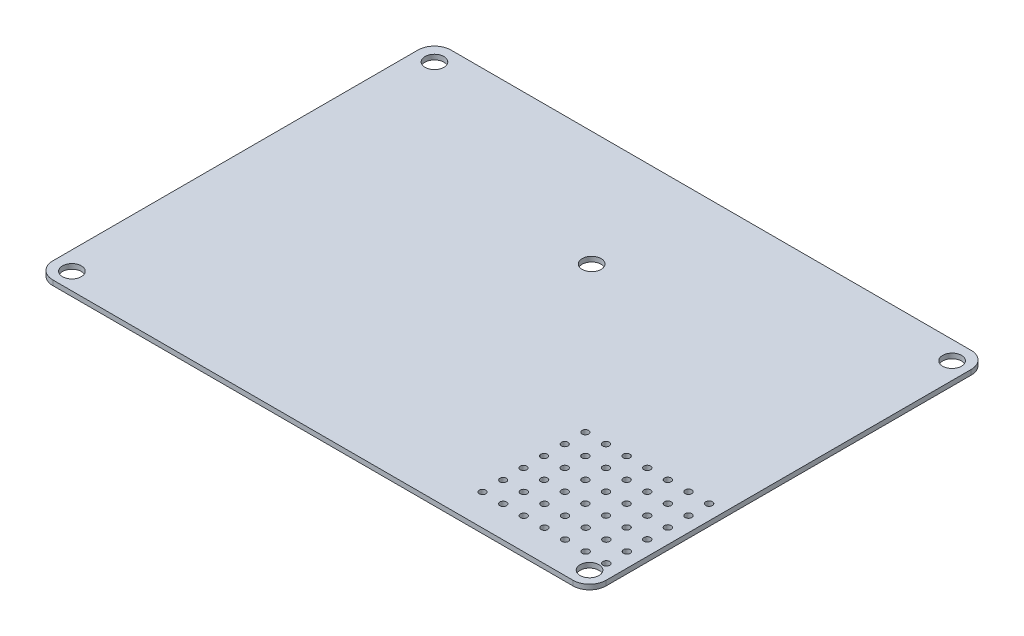
from build123d import *

# Parameters (mm, degrees)
EXTRUSION1_DEPTH        = 1.2
ENL_V_MAT_EXTRU_2_REACH = 3.2
TROUS_FIXATION_R        = 2.286
ESQUISSE4_R             = 0.786015169
ESQUISSE4_R_2           = 0.803384231
ESQUISSE4_R_3           = 0.807067653
ESQUISSE4_R_4           = 0.813396678
ENL_V_MAT_EXTRU_3_DEPTH = 1.2


with BuildPart() as part:
    # Carte → Extrusion1 (new body)
    with BuildSketch(Plane(origin=(0, 0, 0), x_dir=(1, 0, 0), z_dir=(0, 1, 0))):
        with BuildLine():
            Line((4, 0), (130.112, 0))
            ThreePointArc((130.112, 0), (132.940427125, -1.171572875), (134.112, -4))
            Line((134.112, -4), (134.112, -92.52))
            ThreePointArc((134.112, -92.52), (132.940427125, -95.348427125), (130.112, -96.52))
            Line((130.112, -96.52), (4, -96.52))
            ThreePointArc((4, -96.52), (1.171572875, -95.348427125), (0, -92.52))
            Line((0, -92.52), (0, -4))
            ThreePointArc((0, -4), (1.171572875, -1.171572875), (4, 0))
        make_face()
    extrude(amount=EXTRUSION1_DEPTH)

    # Trous fixation → Enlèv. mat.-Extru.2 (cut, up to next)
    with BuildSketch(Plane(origin=(0, 1.2, 0), x_dir=(1, 0, 0), z_dir=(0, 1, 0)), mode=Mode.PRIVATE) as enl_v_mat_extru_2_sk1:
        with Locations((4.5, -4.5)):
            Circle(TROUS_FIXATION_R)
    enl_v_mat_extru_2_tool1 = extrude(enl_v_mat_extru_2_sk1.sketch, amount=-ENL_V_MAT_EXTRU_2_REACH, mode=Mode.PRIVATE) & part.part
    add(enl_v_mat_extru_2_tool1.solids().sort_by_distance((4.5, 1.2, 4.5))[0], mode=Mode.SUBTRACT)
    # Trous fixation → Enlèv. mat.-Extru.2 (cut, up to next)
    with BuildSketch(Plane(origin=(0, 1.2, 0), x_dir=(1, 0, 0), z_dir=(0, 1, 0)), mode=Mode.PRIVATE) as enl_v_mat_extru_2_sk2:
        with Locations((129.976, -4.5)):
            Circle(TROUS_FIXATION_R)
    enl_v_mat_extru_2_tool2 = extrude(enl_v_mat_extru_2_sk2.sketch, amount=-ENL_V_MAT_EXTRU_2_REACH, mode=Mode.PRIVATE) & part.part
    add(enl_v_mat_extru_2_tool2.solids().sort_by_distance((129.976, 1.2, 4.5))[0], mode=Mode.SUBTRACT)
    # Trous fixation → Enlèv. mat.-Extru.2 (cut, up to next)
    with BuildSketch(Plane(origin=(0, 1.2, 0), x_dir=(1, 0, 0), z_dir=(0, 1, 0)), mode=Mode.PRIVATE) as enl_v_mat_extru_2_sk3:
        with Locations((129.976, -92.384)):
            Circle(TROUS_FIXATION_R)
    enl_v_mat_extru_2_tool3 = extrude(enl_v_mat_extru_2_sk3.sketch, amount=-ENL_V_MAT_EXTRU_2_REACH, mode=Mode.PRIVATE) & part.part
    add(enl_v_mat_extru_2_tool3.solids().sort_by_distance((129.976, 1.2, 92.384))[0], mode=Mode.SUBTRACT)
    # Trous fixation → Enlèv. mat.-Extru.2 (cut, up to next)
    with BuildSketch(Plane(origin=(0, 1.2, 0), x_dir=(1, 0, 0), z_dir=(0, 1, 0)), mode=Mode.PRIVATE) as enl_v_mat_extru_2_sk4:
        with Locations((4.5, -92.384)):
            Circle(TROUS_FIXATION_R)
    enl_v_mat_extru_2_tool4 = extrude(enl_v_mat_extru_2_sk4.sketch, amount=-ENL_V_MAT_EXTRU_2_REACH, mode=Mode.PRIVATE) & part.part
    add(enl_v_mat_extru_2_tool4.solids().sort_by_distance((4.5, 1.2, 92.384))[0], mode=Mode.SUBTRACT)
    # Trous fixation → Enlèv. mat.-Extru.2 (cut, up to next)
    with BuildSketch(Plane(origin=(0, 1.2, 0), x_dir=(1, 0, 0), z_dir=(0, 1, 0)), mode=Mode.PRIVATE) as enl_v_mat_extru_2_sk5:
        with Locations((65.968, -27.868)):
            Circle(TROUS_FIXATION_R)
    enl_v_mat_extru_2_tool5 = extrude(enl_v_mat_extru_2_sk5.sketch, amount=-ENL_V_MAT_EXTRU_2_REACH, mode=Mode.PRIVATE) & part.part
    add(enl_v_mat_extru_2_tool5.solids().sort_by_distance((65.968, 1.2, 27.868))[0], mode=Mode.SUBTRACT)

    # Esquisse4 → Enlèv. mat.-Extru.3 (cut)
    with BuildSketch(Plane(origin=(0, 1.2, 0), x_dir=(1, 0, 0), z_dir=(0, 1, 0))):
        with Locations((100.522476241, -63.944295872)):
            Circle(ESQUISSE4_R)
        with Locations((105.522476241, -63.944295872)):
            Circle(ESQUISSE4_R_2)
        with Locations((110.522476241, -63.944295872)):
            Circle(ESQUISSE4_R_3)
        with Locations((115.522476241, -63.944295872)):
            Circle(ESQUISSE4_R_2)
        with Locations((120.522476241, -63.944295872)):
            Circle(ESQUISSE4_R_2)
        with Locations((125.522476241, -63.944295872)):
            Circle(ESQUISSE4_R_2)
        with Locations((130.522476241, -63.944295872)):
            Circle(ESQUISSE4_R_4)
        with Locations((125.522476241, -68.944295872)):
            Circle(ESQUISSE4_R_2)
        with Locations((105.522476241, -68.944295872)):
            Circle(ESQUISSE4_R_2)
        with Locations((115.522476241, -68.944295872)):
            Circle(ESQUISSE4_R_2)
        with Locations((100.522476241, -68.944295872)):
            Circle(ESQUISSE4_R)
        with Locations((120.522476241, -68.944295872)):
            Circle(ESQUISSE4_R_2)
        with Locations((110.522476241, -68.944295872)):
            Circle(ESQUISSE4_R_3)
        with Locations((130.522476241, -68.944295872)):
            Circle(ESQUISSE4_R_4)
        with Locations((105.522476241, -78.944295872)):
            Circle(ESQUISSE4_R_2)
        with Locations((115.522476241, -73.944295872)):
            Circle(ESQUISSE4_R_2)
        with Locations((120.522476241, -78.944295872)):
            Circle(ESQUISSE4_R_2)
        with Locations((110.522476241, -73.944295872)):
            Circle(ESQUISSE4_R_3)
        with Locations((100.522476241, -78.944295872)):
            Circle(ESQUISSE4_R)
        with Locations((130.522476241, -73.944295872)):
            Circle(ESQUISSE4_R_4)
        with Locations((130.522476241, -78.944295872)):
            Circle(ESQUISSE4_R_4)
        with Locations((115.522476241, -78.944295872)):
            Circle(ESQUISSE4_R_2)
        with Locations((105.522476241, -73.944295872)):
            Circle(ESQUISSE4_R_2)
        with Locations((125.522476241, -73.944295872)):
            Circle(ESQUISSE4_R_2)
        with Locations((110.522476241, -78.944295872)):
            Circle(ESQUISSE4_R_3)
        with Locations((120.522476241, -73.944295872)):
            Circle(ESQUISSE4_R_2)
        with Locations((125.522476241, -78.944295872)):
            Circle(ESQUISSE4_R_2)
        with Locations((100.522476241, -73.944295872)):
            Circle(ESQUISSE4_R)
        with Locations((100.604087819, -83.944295872)):
            Circle(ESQUISSE4_R)
        with Locations((105.604087819, -83.944295872)):
            Circle(ESQUISSE4_R_2)
        with Locations((110.604087819, -83.944295872)):
            Circle(ESQUISSE4_R_3)
        with Locations((115.604087819, -83.944295872)):
            Circle(ESQUISSE4_R_2)
        with Locations((120.604087819, -83.944295872)):
            Circle(ESQUISSE4_R_2)
        with Locations((125.604087819, -83.944295872)):
            Circle(ESQUISSE4_R_2)
        with Locations((130.604087819, -83.944295872)):
            Circle(ESQUISSE4_R_4)
        with Locations((125.604087819, -88.944295872)):
            Circle(ESQUISSE4_R_2)
        with Locations((105.604087819, -88.944295872)):
            Circle(ESQUISSE4_R_2)
        with Locations((115.604087819, -88.944295872)):
            Circle(ESQUISSE4_R_2)
        with Locations((100.604087819, -88.944295872)):
            Circle(ESQUISSE4_R)
        with Locations((120.604087819, -88.944295872)):
            Circle(ESQUISSE4_R_2)
        with Locations((110.604087819, -88.944295872)):
            Circle(ESQUISSE4_R_3)
        with Locations((130.604087819, -88.944295872)):
            Circle(ESQUISSE4_R_4)
    extrude(amount=-ENL_V_MAT_EXTRU_3_DEPTH, mode=Mode.SUBTRACT)


solid = part.part
